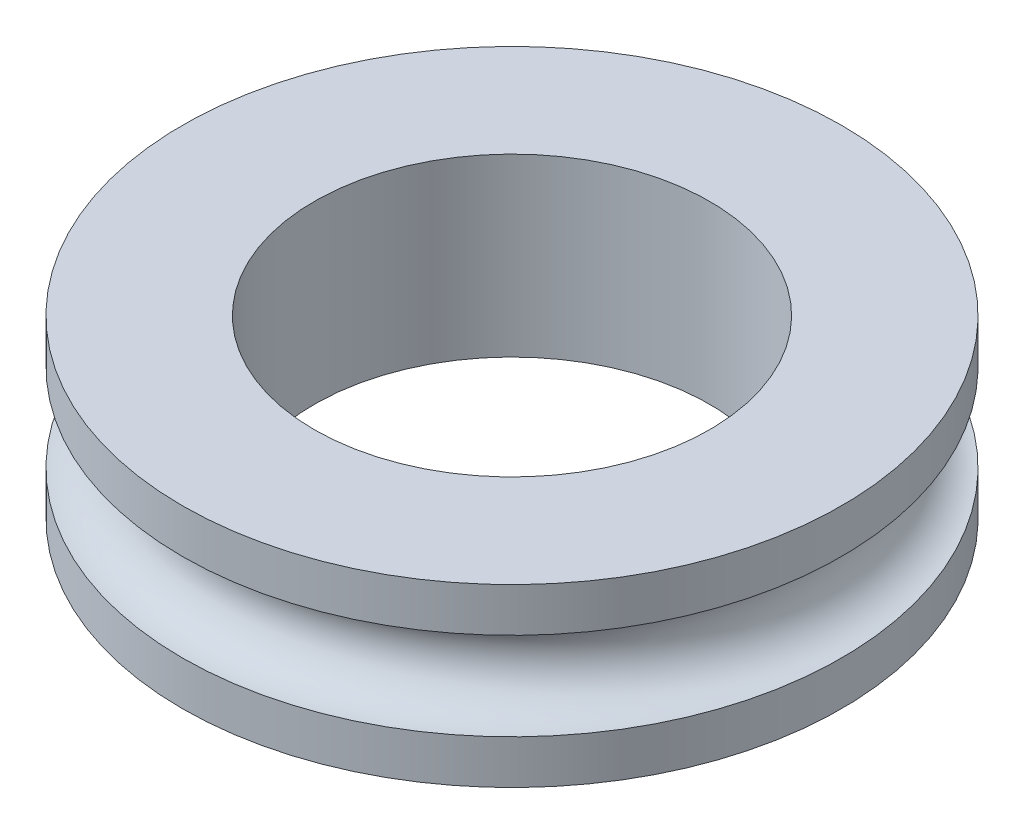
from build123d import *

# Parameters (mm, degrees)
SKETCH1_R           = 7.5
SKETCH1_R_2         = 4.5
BOSS_EXTRUDE1_DEPTH = 4


with BuildPart() as part:
    # Sketch1 → Boss-Extrude1 (new body)
    with BuildSketch(Plane(origin=(0, 0, 0), x_dir=(1, 0, 0), z_dir=(0, 1, 0))):
        Circle(SKETCH1_R)
        Circle(SKETCH1_R_2, mode=Mode.SUBTRACT)
    extrude(amount=BOSS_EXTRUDE1_DEPTH)

    # Sketch3 → Cut-Revolve1 (revolve, cut)
    with BuildSketch(Plane.XY):
        with BuildLine():
            Line((-7.5, 1), (-7.5, 3))
            ThreePointArc((-7.5, 3), (-6.5, 2), (-7.5, 1))
        make_face()
    revolve(axis=Axis((0, 0, 0), (0, 1, 0)), mode=Mode.SUBTRACT)


solid = part.part
